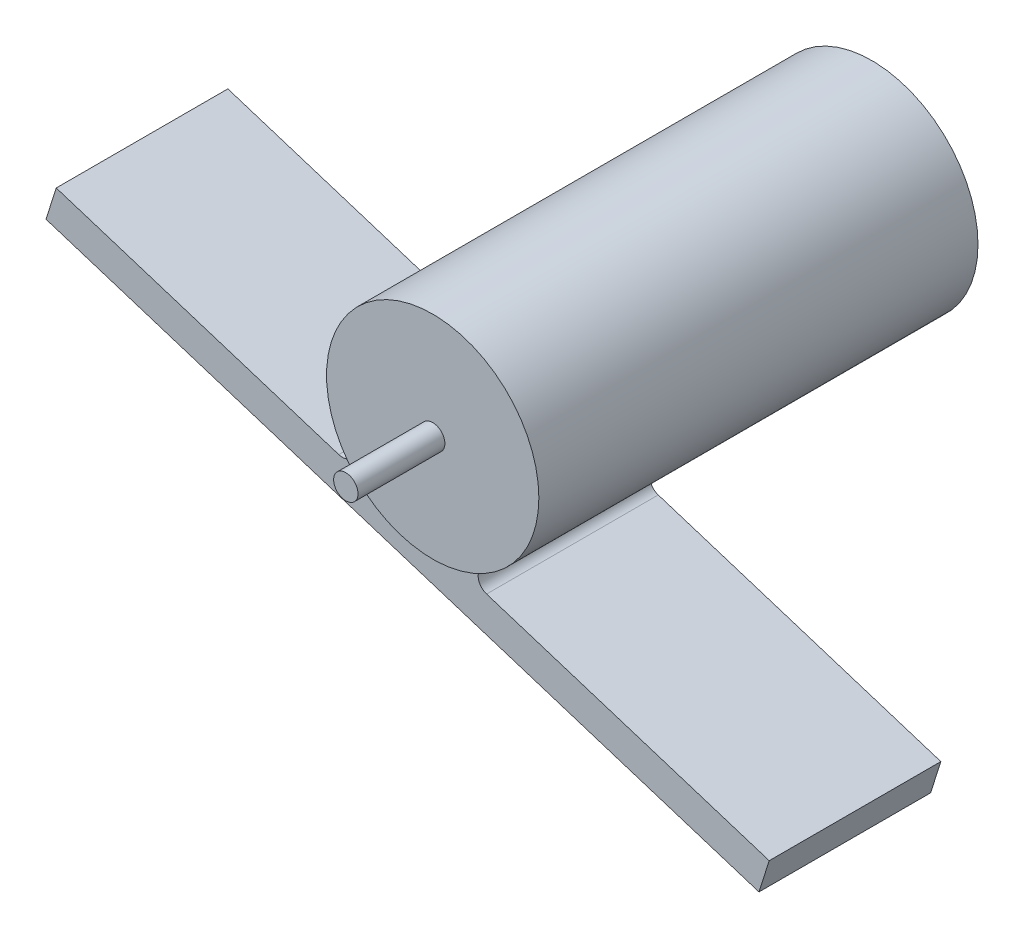
from build123d import *

# Parameters (mm, degrees)
SKETCH1_R                = 22
BOSS_EXTRUDE1_DEPTH      = 91
SKETCH2_R                = 2.525052574
BOSS_EXTRUDE2_DEPTH      = 18
SKETCH4_W                = 155
SKETCH4_H                = 35.569912337
BOSS_EXTRUDE3_DEPTH      = 6
BOSS_EXTRUDE3_DEPTH_BACK = 1
FILLET1_R                = 2.5
FILLET2_R                = 2.5


with BuildPart() as part:
    # Sketch1 → Boss-Extrude1 (new body)
    with BuildSketch(Plane.XY):
        with Locations((-5.492733953, -4.838837054)):
            Circle(SKETCH1_R)
    extrude(amount=BOSS_EXTRUDE1_DEPTH)

    # Sketch2 → Boss-Extrude2 (add)
    with BuildSketch(Plane.XY.offset(91)):
        with Locations((-5.492733953, -4.838837054)):
            Circle(SKETCH2_R)
    extrude(amount=BOSS_EXTRUDE2_DEPTH)

    # Sketch4 → Boss-Extrude3 (add, two sides)
    with BuildSketch(Plane(origin=(-12.142972716, -25.809633996, 91), x_dir=(-0.953218043, 0.30228358, 0), z_dir=(-0.30228358, -0.953218043, 0))) as boss_extrude3_sk:
        with Locations((0, 19.988267876)):
            Rectangle(SKETCH4_W, SKETCH4_H)
    extrude(amount=BOSS_EXTRUDE3_DEPTH)
    extrude(boss_extrude3_sk.sketch, amount=-BOSS_EXTRUDE3_DEPTH_BACK)

    # Fillet1
    fillet1_edges = [part.edges().sort_by_distance(p)[0] for p in [
        (-5.59002042, -26.838621947, 71.011732124),
    ]]
    fillet(fillet1_edges, radius=FILLET1_R)

    # Fillet2
    fillet2_edges = [part.edges().sort_by_distance(p)[0] for p in [
        (-18.091357852, -22.87420996, 71.011732124),
    ]]
    fillet(fillet2_edges, radius=FILLET2_R)


solid = part.part
